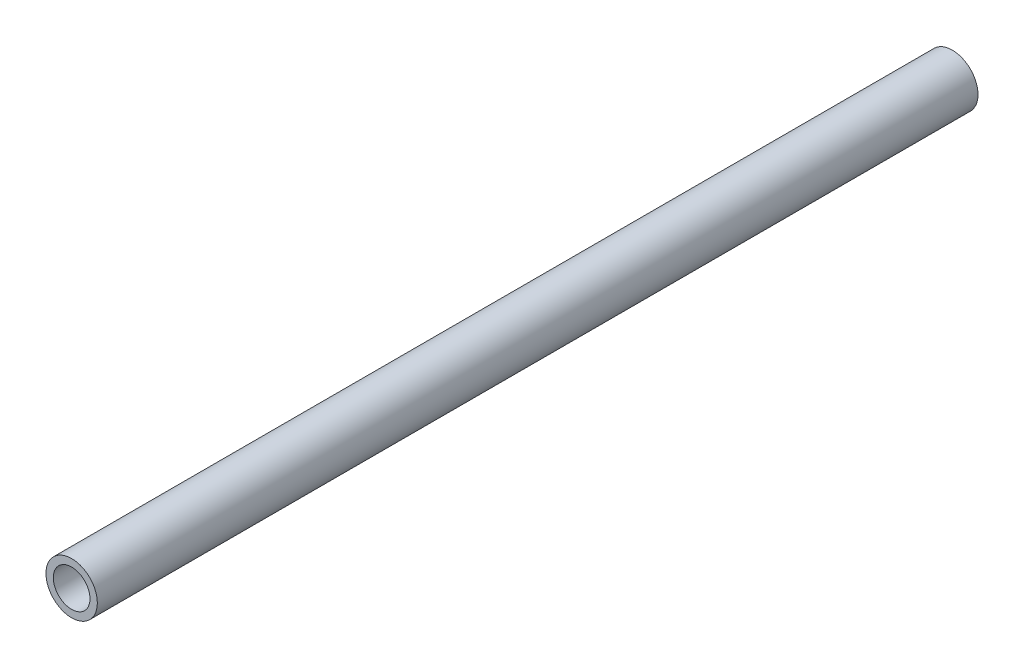
from build123d import *

# Parameters (mm, degrees)
SKETCH1_R           = 13.335
BOSS_EXTRUDE1_DEPTH = 457.2
SKETCH2_R           = 9.525
CUT_EXTRUDE1_DEPTH  = 458.2


with BuildPart() as part:
    # Sketch1 → Boss-Extrude1 (new body)
    with BuildSketch(Plane.XY):
        Circle(SKETCH1_R)
    extrude(amount=BOSS_EXTRUDE1_DEPTH)

    # Sketch2 → Cut-Extrude1 (cut, through all)
    with BuildSketch(Plane(origin=(0, 0, 0), x_dir=(-1, 0, 0), z_dir=(0, 0, -1))):
        Circle(SKETCH2_R)
    extrude(amount=-CUT_EXTRUDE1_DEPTH, mode=Mode.SUBTRACT)


solid = part.part
